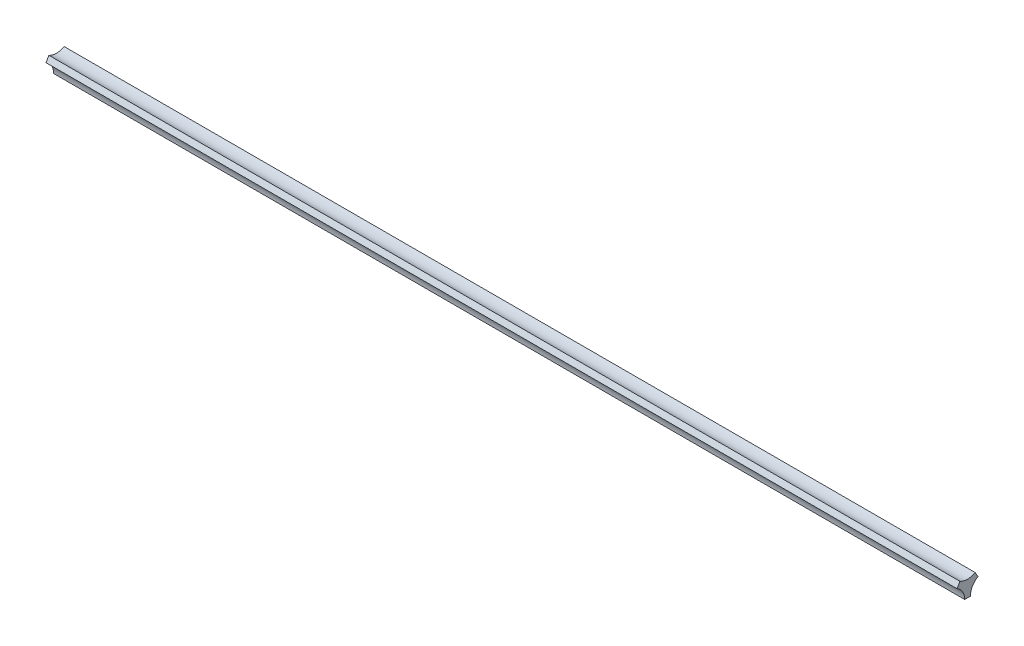
from build123d import *

# Parameters (mm, degrees)
BOSS_EXTRUDE1_DEPTH = 2380


with BuildPart() as part:
    # Sketch1 → Boss-Extrude1 (new body, symmetric)
    with BuildSketch(Plane(origin=(0, 0, 0), x_dir=(0, 0, -1), z_dir=(1, 0, 0))):
        with BuildLine():
            Line((-15, -54.559600438), (15, -54.559600438))
            ThreePointArc((15, -54.559600438), (25.650980399, -14.809600438), (54.75, 14.289419162))
            Line((54.75, 14.289419162), (39.75, 40.270181276))
            ThreePointArc((39.75, 40.270181276), (0, 29.619200877), (-39.75, 40.270181276))
            Line((-39.75, 40.270181276), (-54.75, 14.289419162))
            ThreePointArc((-54.75, 14.289419162), (-25.650980399, -14.809600438), (-15, -54.559600438))
        make_face()
    extrude(amount=BOSS_EXTRUDE1_DEPTH, both=True)


solid = part.part
